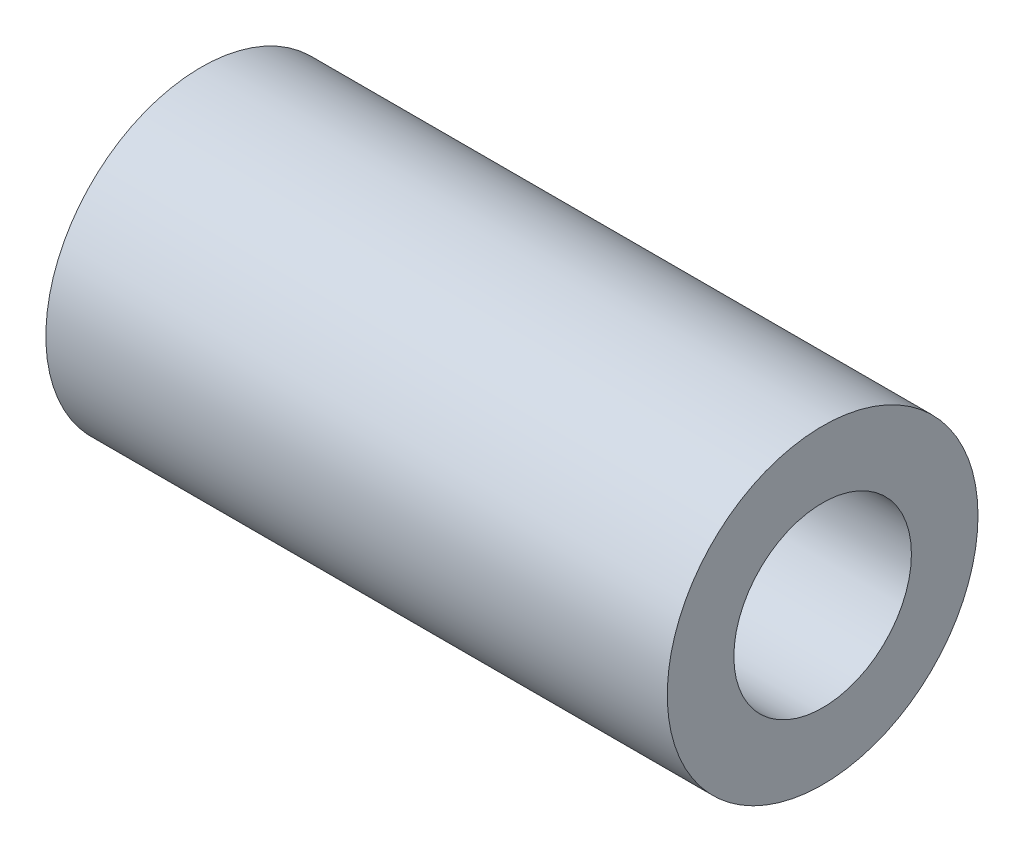
from build123d import *

# Parameters (mm, degrees)
CROQUIS1_R              = 7
CROQUIS1_R_2            = 4
SALIENTE_EXTRUIR1_DEPTH = 14


with BuildPart() as part:
    # Croquis1 → Saliente-Extruir1 (new body, symmetric)
    with BuildSketch(Plane(origin=(0, 0, 0), x_dir=(0, 0, -1), z_dir=(1, 0, 0))):
        Circle(CROQUIS1_R)
        Circle(CROQUIS1_R_2, mode=Mode.SUBTRACT)
    extrude(amount=SALIENTE_EXTRUIR1_DEPTH, both=True)


solid = part.part
